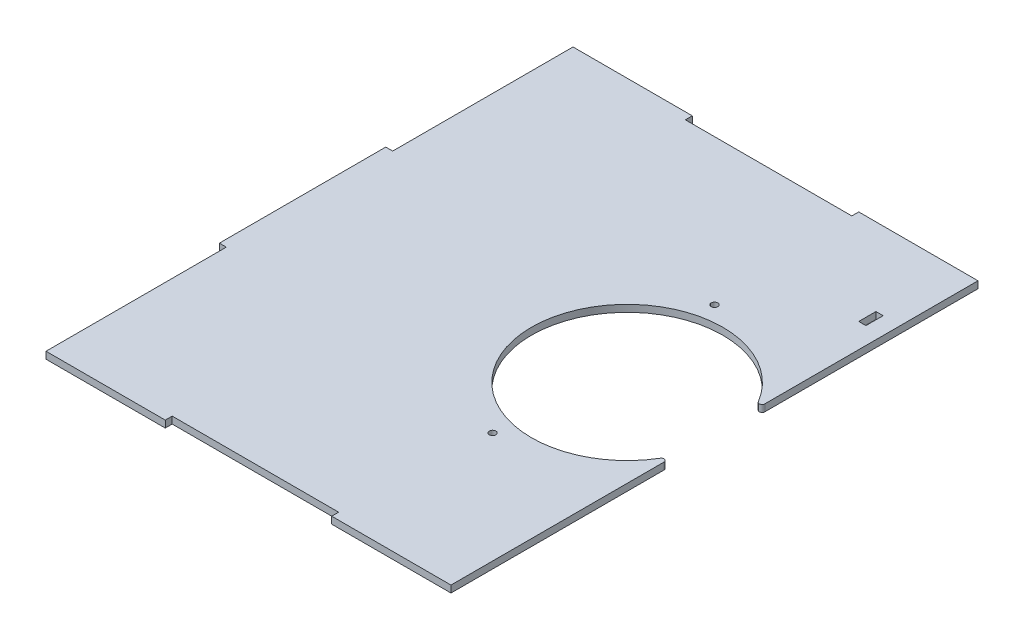
from build123d import *

# Parameters (mm, degrees)
SKETCH1_W           = 185.42
SKETCH1_H           = 241.3
BOSS_EXTRUDE1_DEPTH = 3.175
SKETCH2_R           = 43.815
CUT_EXTRUDE1_DEPTH  = 4.175
SKETCH7_R           = 1.5
CUT_EXTRUDE4_DEPTH  = 4.175
FILLET1_R           = 1.27
SKETCH8_W           = 76.2
SKETCH8_H           = 3.175
CUT_EXTRUDE5_DEPTH  = 4.175
SKETCH11_W          = 3.175
SKETCH11_H          = 76.2
BOSS_EXTRUDE3_DEPTH = 3.175
SKETCH12_W          = 3.302
SKETCH12_H          = 7.874
CUT_EXTRUDE6_DEPTH  = 4.175


with BuildPart() as part:
    # Sketch1 → Boss-Extrude1 (new body)
    with BuildSketch(Plane(origin=(0, 0, 0), x_dir=(1, 0, 0), z_dir=(0, 1, 0))):
        with Locations((92.71, 120.65)):
            Rectangle(SKETCH1_W, SKETCH1_H)
    extrude(amount=BOSS_EXTRUDE1_DEPTH)

    # Sketch2 → Cut-Extrude1 (cut, through all)
    with BuildSketch(Plane(origin=(0, 3.175, 0), x_dir=(1, 0, 0), z_dir=(0, 1, 0))):
        with Locations((145.415, 120.65)):
            Circle(SKETCH2_R)
    extrude(amount=-CUT_EXTRUDE1_DEPTH, mode=Mode.SUBTRACT)

    # Sketch7 → Cut-Extrude4 (cut, through all)
    with BuildSketch(Plane(origin=(0, 3.175, 0), x_dir=(1, 0, 0), z_dir=(0, 1, 0))):
        with Locations((134.62, 171.45)):
            Circle(SKETCH7_R)
        with Locations((134.62, 69.85)):
            Circle(SKETCH7_R)
    extrude(amount=-CUT_EXTRUDE4_DEPTH, mode=Mode.SUBTRACT)

    # Fillet1
    fillet1_edges = [part.edges().sort_by_distance(p)[0] for p in [
        (185.42, 1.5875, -102.779515955),
        (185.42, 1.5875, -138.520484045),
    ]]
    fillet(fillet1_edges, radius=FILLET1_R)

    # Sketch8 → Cut-Extrude5 (cut, through all)
    with BuildSketch(Plane(origin=(0, 3.175, 0), x_dir=(1, 0, 0), z_dir=(0, 1, 0))):
        with Locations((92.71, 239.7125)):
            Rectangle(SKETCH8_W, SKETCH8_H)
        with Locations((92.71, 1.5875)):
            Rectangle(SKETCH8_W, SKETCH8_H)
    extrude(amount=-CUT_EXTRUDE5_DEPTH, mode=Mode.SUBTRACT)

    # Sketch11 → Boss-Extrude3 (add)
    with BuildSketch(Plane(origin=(0, 3.175, 0), x_dir=(1, 0, 0), z_dir=(0, 1, 0))):
        with Locations((-1.5875, 120.65)):
            Rectangle(SKETCH11_W, SKETCH11_H)
    extrude(amount=-BOSS_EXTRUDE3_DEPTH)

    # Sketch12 → Cut-Extrude6 (cut, through all)
    with BuildSketch(Plane(origin=(0, 3.175, 0), x_dir=(1, 0, 0), z_dir=(0, 1, 0))):
        with Locations((175.895, 201.803)):
            Rectangle(SKETCH12_W, SKETCH12_H)
    extrude(amount=-CUT_EXTRUDE6_DEPTH, mode=Mode.SUBTRACT)


solid = part.part
